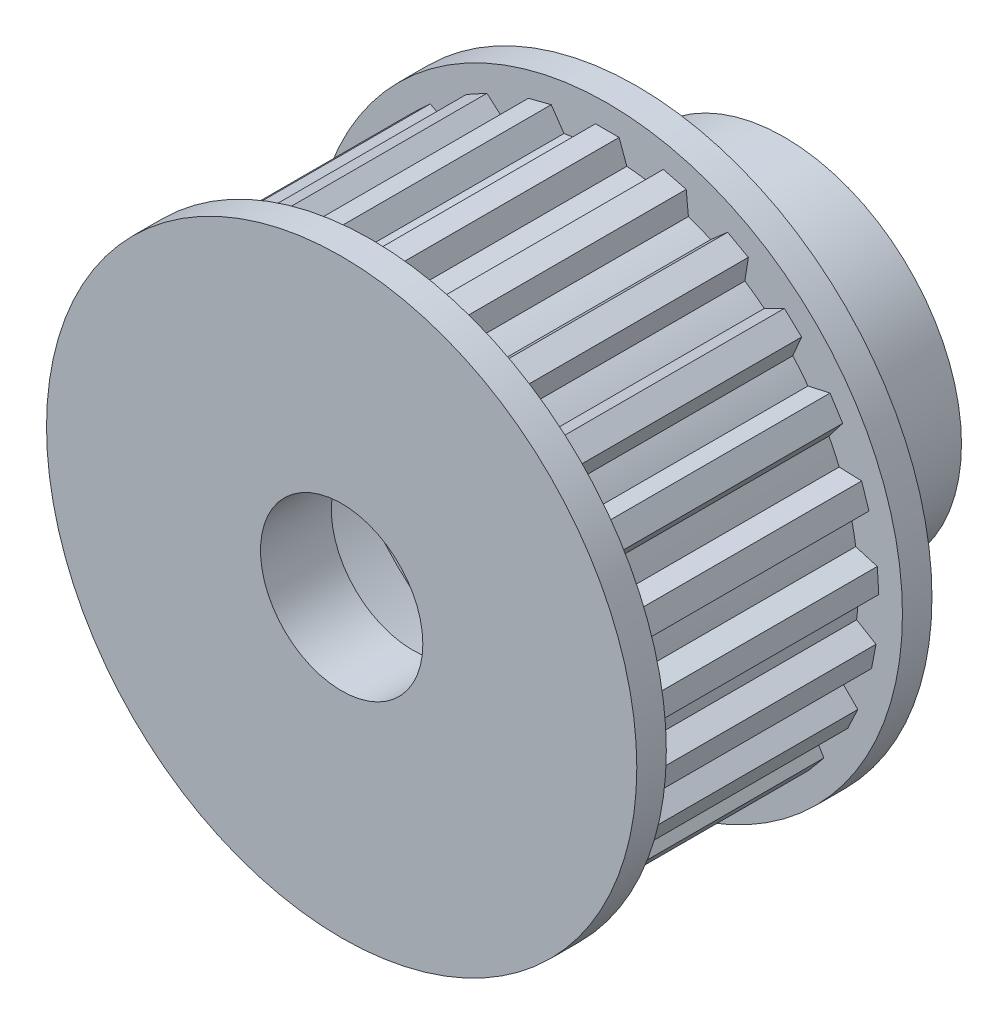
from build123d import *

# Parameters (mm, degrees)
BOSS_EXTRUDE1_DEPTH = 5
SKETCH2_R           = 10
BOSS_EXTRUDE2_DEPTH = 1
SKETCH4_R           = 6
BOSS_EXTRUDE3_DEPTH = 5
CUT_EXTRUDE1_REACH  = 17
SKETCH5_R           = 2.75
SKETCH7_R           = 8.1
CUT_EXTRUDE2_DEPTH  = 2.6


with BuildPart() as part:
    # Sketch1 → Boss-Extrude1 (new body, symmetric)
    with BuildSketch(Plane.XY):
        with BuildLine():
            Line((-0.4, 9.191300234), (-0.660980834, 8.474261286))
            ThreePointArc((-0.660980834, 8.474261286), (-1.065332485, 8.432974961), (-1.467248177, 8.372406033))
            Line((-1.467248177, 8.372406033), (-1.898350154, 9.002014591))
            Line((-1.898350154, 9.002014591), (-2.673216683, 8.803062681))
            Line((-2.673216683, 8.803062681), (-2.747677989, 8.043647535))
            ThreePointArc((-2.747677989, 8.043647535), (-3.129058698, 7.90310013), (-3.503284589, 7.744481718))
            Line((-3.503284589, 7.744481718), (-4.077419986, 8.247099263))
            Line((-4.077419986, 8.247099263), (-4.77846533, 7.861696324))
            Line((-4.77846533, 7.861696324), (-4.66172843, 7.107621828))
            ThreePointArc((-4.66172843, 7.107621828), (-4.996174644, 6.876644452), (-5.319196746, 6.629943135))
            Line((-5.319196746, 6.629943135), (-6.000290524, 6.973988359))
            Line((-6.000290524, 6.973988359), (-6.583465426, 6.426350674))
            Line((-6.583465426, 6.426350674), (-6.282865329, 5.724998101))
            ThreePointArc((-6.282865329, 5.724998101), (-6.549362564, 5.418103913), (-6.80088421, 5.098820841))
            Line((-6.80088421, 5.098820841), (-7.546140742, 5.262676117))
            Line((-7.546140742, 5.262676117), (-7.974802178, 4.587213776))
            Line((-7.974802178, 4.587213776), (-7.509226693, 3.982651688))
            ThreePointArc((-7.509226693, 3.982651688), (-7.691029946, 3.619123978), (-7.855247106, 3.247320882))
            Line((-7.855247106, 3.247320882), (-8.617839183, 3.220690579))
            Line((-8.617839183, 3.220690579), (-8.865052779, 2.459845366))
            Line((-8.865052779, 2.459845366), (-8.263755727, 1.990060623))
            ThreePointArc((-8.263755727, 1.990060623), (-8.349441631, 1.592741174), (-8.416035937, 1.191779808))
            Line((-8.416035937, 1.191779808), (-9.148047095, 0.976337208))
            Line((-9.148047095, 0.976337208), (-9.198279511, 0.177915826))
            Line((-9.198279511, 0.177915826), (-8.499042597, -0.127573271))
            ThreePointArc((-8.499042597, -0.127573271), (-8.483227192, -0.533719416), (-8.448014278, -0.938645173))
            Line((-8.448014278, -0.938645173), (-9.103449564, -1.32936302))
            Line((-9.103449564, -1.32936302), (-8.953544512, -2.115192821))
            Line((-8.953544512, -2.115192821), (-8.200303363, -2.237191266))
            ThreePointArc((-8.200303363, -2.237191266), (-8.083980389, -2.626644452), (-7.949172812, -3.010091627))
            Line((-7.949172812, -3.010091627), (-8.486848816, -3.551534481))
            Line((-8.486848816, -3.551534481), (-8.146225383, -4.275396123))
            Line((-8.146225383, -4.275396123), (-7.38630891, -4.206238307))
            ThreePointArc((-7.38630891, -4.206238307), (-7.176787367, -4.554527757), (-6.950855584, -4.892402953))
            Line((-6.950855584, -4.892402953), (-7.336988145, -5.550549969))
            Line((-7.336988145, -5.550549969), (-6.827048953, -6.166960564))
            Line((-6.827048953, -6.166960564), (-6.108205503, -5.910991925))
            ThreePointArc((-6.108205503, -5.910991925), (-5.8186504, -6.196233333), (-5.515790536, -6.467306608))
            Line((-5.515790536, -6.467306608), (-5.726117525, -7.200803989))
            Line((-5.726117525, -7.200803989), (-5.078903929, -7.671032191))
            Line((-5.078903929, -7.671032191), (-4.44630108, -7.244336181))
            ThreePointArc((-4.44630108, -7.244336181), (-4.09490623, -7.44860678), (-3.734148082, -7.635845605))
            Line((-3.734148082, -7.635845605), (-3.755453882, -8.398605012))
            Line((-3.755453882, -8.398605012), (-3.011632693, -8.693104654))
            Line((-3.011632693, -8.693104654), (-2.505019208, -8.122492153))
            ThreePointArc((-2.505019208, -8.122492153), (-2.113864041, -8.23295687), (-1.717875372, -8.324596339))
            Line((-1.717875372, -8.324596339), (-1.54882126, -9.068690793))
            Line((-1.54882126, -9.068690793), (-0.755129499, -9.16895738))
            Line((-0.755129499, -9.16895738), (-0.406337766, -8.49028207))
            ThreePointArc((-0.406337766, -8.49028207), (0, -8.5), (0.406337766, -8.49028207))
            Line((0.406337766, -8.49028207), (0.755129499, -9.16895738))
            Line((0.755129499, -9.16895738), (1.54882126, -9.068690793))
            Line((1.54882126, -9.068690793), (1.717875372, -8.324596339))
            ThreePointArc((1.717875372, -8.324596339), (2.113864041, -8.23295687), (2.505019208, -8.122492153))
            Line((2.505019208, -8.122492153), (3.011632693, -8.693104654))
            Line((3.011632693, -8.693104654), (3.755453882, -8.398605012))
            Line((3.755453882, -8.398605012), (3.734148082, -7.635845605))
            ThreePointArc((3.734148082, -7.635845605), (4.09490623, -7.44860678), (4.44630108, -7.244336181))
            Line((4.44630108, -7.244336181), (5.078903929, -7.671032191))
            Line((5.078903929, -7.671032191), (5.726117525, -7.200803989))
            Line((5.726117525, -7.200803989), (5.515790536, -6.467306608))
            ThreePointArc((5.515790536, -6.467306608), (5.8186504, -6.196233333), (6.108205503, -5.910991925))
            Line((6.108205503, -5.910991925), (6.827048953, -6.166960564))
            Line((6.827048953, -6.166960564), (7.336988145, -5.550549969))
            Line((7.336988145, -5.550549969), (6.950855584, -4.892402953))
            ThreePointArc((6.950855584, -4.892402953), (7.176787367, -4.554527757), (7.38630891, -4.206238307))
            Line((7.38630891, -4.206238307), (8.146225383, -4.275396123))
            Line((8.146225383, -4.275396123), (8.486848816, -3.551534481))
            Line((8.486848816, -3.551534481), (7.949172812, -3.010091627))
            ThreePointArc((7.949172812, -3.010091627), (8.083980389, -2.626644452), (8.200303363, -2.237191266))
            Line((8.200303363, -2.237191266), (8.953544512, -2.115192821))
            Line((8.953544512, -2.115192821), (9.103449564, -1.32936302))
            Line((9.103449564, -1.32936302), (8.448014278, -0.938645173))
            ThreePointArc((8.448014278, -0.938645173), (8.483227192, -0.533719416), (8.499042597, -0.127573271))
            Line((8.499042597, -0.127573271), (9.198279511, 0.177915826))
            Line((9.198279511, 0.177915826), (9.148047095, 0.976337208))
            Line((9.148047095, 0.976337208), (8.416035937, 1.191779808))
            ThreePointArc((8.416035937, 1.191779808), (8.349441631, 1.592741174), (8.263755727, 1.990060623))
            Line((8.263755727, 1.990060623), (8.865052779, 2.459845366))
            Line((8.865052779, 2.459845366), (8.617839183, 3.220690579))
            Line((8.617839183, 3.220690579), (7.855247106, 3.247320882))
            ThreePointArc((7.855247106, 3.247320882), (7.691029946, 3.619123978), (7.509226693, 3.982651688))
            Line((7.509226693, 3.982651688), (7.974802178, 4.587213776))
            Line((7.974802178, 4.587213776), (7.546140742, 5.262676117))
            Line((7.546140742, 5.262676117), (6.80088421, 5.098820841))
            ThreePointArc((6.80088421, 5.098820841), (6.549362564, 5.418103913), (6.282865329, 5.724998101))
            Line((6.282865329, 5.724998101), (6.583465426, 6.426350674))
            Line((6.583465426, 6.426350674), (6.000290524, 6.973988359))
            Line((6.000290524, 6.973988359), (5.319196746, 6.629943135))
            ThreePointArc((5.319196746, 6.629943135), (4.996174644, 6.876644452), (4.66172843, 7.107621828))
            Line((4.66172843, 7.107621828), (4.77846533, 7.861696324))
            Line((4.77846533, 7.861696324), (4.077419986, 8.247099263))
            Line((4.077419986, 8.247099263), (3.503284589, 7.744481718))
            ThreePointArc((3.503284589, 7.744481718), (3.129058698, 7.90310013), (2.747677989, 8.043647535))
            Line((2.747677989, 8.043647535), (2.673216683, 8.803062681))
            Line((2.673216683, 8.803062681), (1.898350154, 9.002014591))
            Line((1.898350154, 9.002014591), (1.467248177, 8.372406033))
            ThreePointArc((1.467248177, 8.372406033), (1.065332485, 8.432974961), (0.660980834, 8.474261286))
            Line((0.660980834, 8.474261286), (0.4, 9.191300234))
            Line((0.4, 9.191300234), (-0.4, 9.191300234))
        make_face()
    extrude(amount=BOSS_EXTRUDE1_DEPTH, both=True)

    # Sketch2 → Boss-Extrude2 (add)
    with BuildSketch(Plane.XY.offset(5)):
        Circle(SKETCH2_R)
    boss_extrude2 = extrude(amount=-BOSS_EXTRUDE2_DEPTH)

    # Mirror1: Boss-Extrude2 across plane
    add(boss_extrude2.mirror(Plane.XY))

    # Sketch4 → Boss-Extrude3 (add)
    with BuildSketch(Plane(origin=(0, 0, -5), x_dir=(-1, 0, 0), z_dir=(0, 0, -1))):
        Circle(SKETCH4_R)
    extrude(amount=BOSS_EXTRUDE3_DEPTH)

    # Sketch5 → Cut-Extrude1 (cut, up to next)
    with BuildSketch(Plane.XY.offset(5), mode=Mode.PRIVATE) as cut_extrude1_sk1:
        Circle(SKETCH5_R)
    cut_extrude1_tool1 = extrude(cut_extrude1_sk1.sketch, amount=-CUT_EXTRUDE1_REACH, mode=Mode.PRIVATE) & part.part
    add(cut_extrude1_tool1.solids().sort_by_distance((0, 0, 5))[0], mode=Mode.SUBTRACT)

    # Sketch7 → Cut-Extrude2 (cut, symmetric)
    with BuildSketch(Plane.XY):
        Circle(SKETCH7_R)
    extrude(amount=CUT_EXTRUDE2_DEPTH, both=True, mode=Mode.SUBTRACT)


solid = part.part
